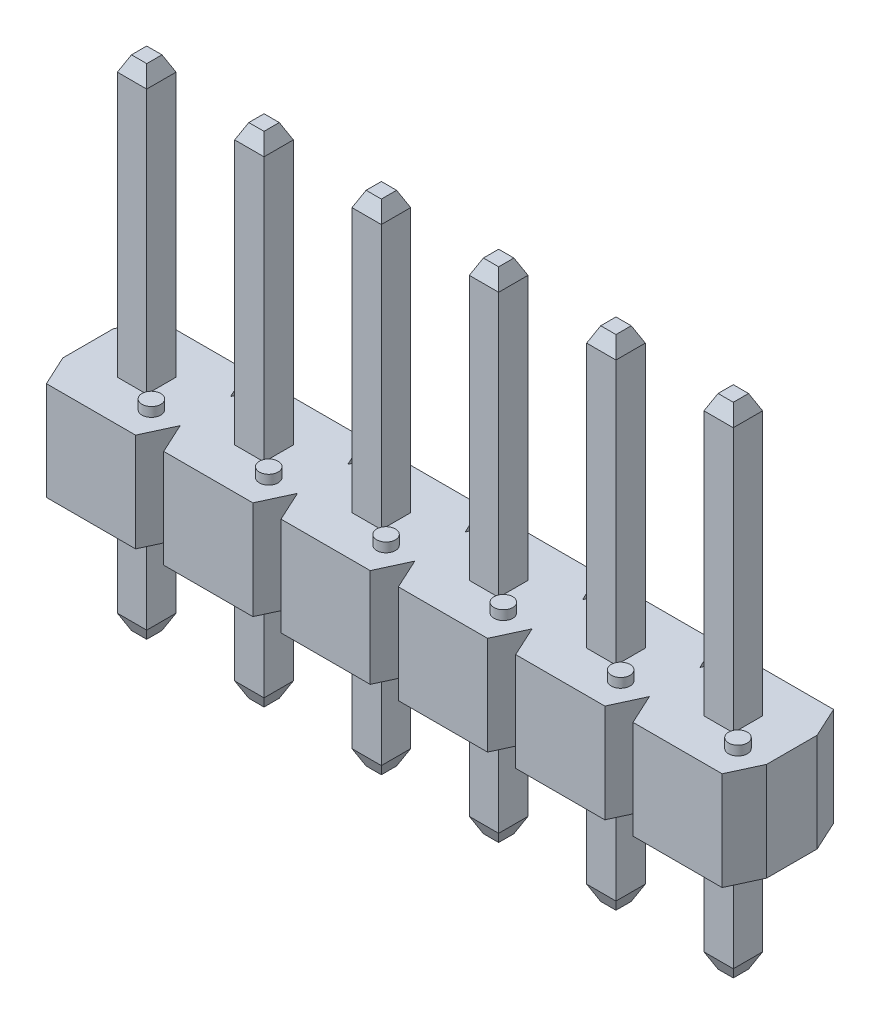
from build123d import *

# Parameters (mm, degrees)
SKETCH1_W              = 15.24
SKETCH1_H              = 2.413
BOSS_EXTRUDE1_DEPTH    = 2.1336
CUT_EXTRUDE1_DEPTH     = 3.1336
CUT_EXTRUDE2_DEPTH     = 3.1336
CUT_EXTRUDE3_DEPTH     = 3.1336
CUT_EXTRUDE4_DEPTH     = 3.1336
CUT_EXTRUDE5_DEPTH     = 3.1336
CUT_EXTRUDE6_DEPTH     = 3.1336
CUT_EXTRUDE7_DEPTH     = 3.1336
CUT_EXTRUDE8_DEPTH     = 3.1336
CUT_EXTRUDE9_DEPTH     = 3.1336
CUT_EXTRUDE10_DEPTH    = 3.1336
SKETCH12_W             = 0.635
SKETCH12_H             = 0.635
BOSS_EXTRUDE2_DEPTH    = 6.0452
SKETCH13_W             = 0.635
SKETCH13_H             = 0.635
BOSS_EXTRUDE3_DEPTH    = 6.0452
SKETCH14_W             = 0.635
SKETCH14_H             = 0.635
BOSS_EXTRUDE4_DEPTH    = 6.0452
SKETCH15_W             = 0.635
SKETCH15_H             = 0.635
BOSS_EXTRUDE5_DEPTH    = 6.0452
SKETCH16_W             = 0.635
SKETCH16_H             = 0.635
BOSS_EXTRUDE6_DEPTH    = 6.0452
SKETCH17_W             = 0.635
SKETCH17_H             = 0.635
BOSS_EXTRUDE7_DEPTH    = 6.0452
SKETCH18_W             = 0.635
SKETCH18_H             = 0.635
BOSS_EXTRUDE8_DEPTH    = 2.6162
SKETCH19_W             = 0.635
SKETCH19_H             = 0.635
BOSS_EXTRUDE9_DEPTH    = 2.6162
SKETCH20_W             = 0.635
SKETCH20_H             = 0.635
BOSS_EXTRUDE10_DEPTH   = 2.6162
SKETCH21_W             = 0.635
SKETCH21_H             = 0.635
BOSS_EXTRUDE11_DEPTH   = 2.6162
SKETCH22_W             = 0.635
SKETCH22_H             = 0.635
BOSS_EXTRUDE12_DEPTH   = 2.6162
SKETCH23_W             = 0.635
SKETCH23_H             = 0.635
BOSS_EXTRUDE13_DEPTH   = 2.6162
DRAFT1_ANGLE           = 24.775140569
DRAFT2_ANGLE           = 24.775140569
DRAFT3_ANGLE           = 24.775140569
DRAFT4_ANGLE           = 24.775140569
DRAFT5_ANGLE           = 24.775140569
DRAFT6_ANGLE           = 24.775140569
SKETCH24_W             = 0.2032
SKETCH24_H             = 0.2032
SKETCH25_W             = 0.2032
SKETCH25_H             = 0.2032
SKETCH26_W             = 0.2032
SKETCH26_H             = 0.2032
SKETCH27_W             = 0.2032
SKETCH27_H             = 0.2032
SKETCH28_W             = 0.2032
SKETCH28_H             = 0.2032
SKETCH29_W             = 0.2032
SKETCH29_H             = 0.2032
SKETCH30_W             = 0.2032
SKETCH30_H             = 0.2032
SKETCH31_W             = 0.2032
SKETCH31_H             = 0.2032
SKETCH32_W             = 0.2032
SKETCH32_H             = 0.2032
SKETCH33_W             = 0.2032
SKETCH33_H             = 0.2032
SKETCH34_W             = 0.2032
SKETCH34_H             = 0.2032
SKETCH35_W             = 0.2032
SKETCH35_H             = 0.2032
SKETCH36_W             = 0.2032
SKETCH36_H             = 0.2032
SKETCH37_W             = 0.2032
SKETCH37_H             = 0.2032
SKETCH38_W             = 0.2032
SKETCH38_H             = 0.2032
SKETCH39_W             = 0.2032
SKETCH39_H             = 0.2032
SKETCH40_W             = 0.2032
SKETCH40_H             = 0.2032
SKETCH41_W             = 0.2032
SKETCH41_H             = 0.2032
SKETCH42_W             = 0.2032
SKETCH42_H             = 0.2032
SKETCH43_W             = 0.2032
SKETCH43_H             = 0.2032
SKETCH44_W             = 0.2032
SKETCH44_H             = 0.2032
SKETCH45_W             = 0.2032
SKETCH45_H             = 0.2032
SKETCH46_W             = 0.2032
SKETCH46_H             = 0.2032
SKETCH47_W             = 0.2032
SKETCH47_H             = 0.2032
CHAMFER1_SIZE          = 0.3048
CHAMFER1_SIZE2         = 0.6604
CHAMFER1_PART_2_SIZE   = 0.3048
CHAMFER1_PART_2_SIZE2  = 0.6604
CHAMFER2_SIZE          = 0.6604
CHAMFER2_SIZE2         = 0.3048
CHAMFER2_PART_2_SIZE   = 0.6604
CHAMFER2_PART_2_SIZE2  = 0.3048
CHAMFER3_SIZE          = 0.1524
CHAMFER3_SIZE2         = 0.32512
CHAMFER3_PART_2_SIZE   = 0.1524
CHAMFER3_PART_2_SIZE2  = 0.32512
CHAMFER3_PART_3_SIZE   = 0.1524
CHAMFER3_PART_3_SIZE2  = 0.32512
CHAMFER3_PART_4_SIZE   = 0.1524
CHAMFER3_PART_4_SIZE2  = 0.32512
CHAMFER3_PART_5_SIZE   = 0.1524
CHAMFER3_PART_5_SIZE2  = 0.32512
CHAMFER3_PART_6_SIZE   = 0.1524
CHAMFER3_PART_6_SIZE2  = 0.32512
CHAMFER3_PART_7_SIZE   = 0.1524
CHAMFER3_PART_7_SIZE2  = 0.32512
CHAMFER3_PART_8_SIZE   = 0.1524
CHAMFER3_PART_8_SIZE2  = 0.32512
CHAMFER3_PART_9_SIZE   = 0.1524
CHAMFER3_PART_9_SIZE2  = 0.32512
CHAMFER3_PART_10_SIZE  = 0.1524
CHAMFER3_PART_10_SIZE2 = 0.32512
CHAMFER3_PART_11_SIZE  = 0.1524
CHAMFER3_PART_11_SIZE2 = 0.32512
CHAMFER3_PART_12_SIZE  = 0.1524
CHAMFER3_PART_12_SIZE2 = 0.32512


with BuildPart() as part:
    # Sketch1 → Boss-Extrude1 (new body)
    with BuildSketch(Plane(origin=(0, 2.1336, 0), x_dir=(1, 0, 0), z_dir=(0, 1, 0))):
        with Locations((6.35, 0)):
            Rectangle(SKETCH1_W, SKETCH1_H)
    extrude(amount=-BOSS_EXTRUDE1_DEPTH)

    # Sketch2 → Cut-Extrude1 (cut, through all)
    with BuildSketch(Plane.XZ):
        Polygon((11.7348, 1.2065), (11.1252, 1.2065), (11.7348, -0.1143), align=None)
    extrude(amount=-CUT_EXTRUDE1_DEPTH, mode=Mode.SUBTRACT)

    # Sketch3 → Cut-Extrude2 (cut, through all)
    with BuildSketch(Plane.XZ):
        Polygon((11.1252, -1.2065), (11.7348, -1.2065), (11.1252, 0.1143), align=None)
    extrude(amount=-CUT_EXTRUDE2_DEPTH, mode=Mode.SUBTRACT)

    # Sketch4 → Cut-Extrude3 (cut, through all)
    with BuildSketch(Plane.XZ):
        Polygon((8.5852, -1.2065), (9.1948, -1.2065), (9.1948, 0.1143), align=None)
    extrude(amount=-CUT_EXTRUDE3_DEPTH, mode=Mode.SUBTRACT)

    # Sketch5 → Cut-Extrude4 (cut, through all)
    with BuildSketch(Plane.XZ):
        Polygon((6.0452, -1.2065), (6.6548, -1.2065), (6.0452, 0.1143), align=None)
    extrude(amount=-CUT_EXTRUDE4_DEPTH, mode=Mode.SUBTRACT)

    # Sketch6 → Cut-Extrude5 (cut, through all)
    with BuildSketch(Plane.XZ):
        Polygon((3.5052, -1.2065), (4.1148, -1.2065), (4.1148, 0.1143), align=None)
    extrude(amount=-CUT_EXTRUDE5_DEPTH, mode=Mode.SUBTRACT)

    # Sketch7 → Cut-Extrude6 (cut, through all)
    with BuildSketch(Plane.XZ):
        Polygon((0.9652, -1.2065), (1.5748, -1.2065), (0.9652, 0.1143), align=None)
    extrude(amount=-CUT_EXTRUDE6_DEPTH, mode=Mode.SUBTRACT)

    # Sketch8 → Cut-Extrude7 (cut, through all)
    with BuildSketch(Plane.XZ):
        Polygon((1.5748, 1.2065), (0.9652, 1.2065), (1.5748, -0.1143), align=None)
    extrude(amount=-CUT_EXTRUDE7_DEPTH, mode=Mode.SUBTRACT)

    # Sketch9 → Cut-Extrude8 (cut, through all)
    with BuildSketch(Plane.XZ):
        Polygon((4.1148, 1.2065), (3.5052, 1.2065), (3.5052, -0.1143), align=None)
    extrude(amount=-CUT_EXTRUDE8_DEPTH, mode=Mode.SUBTRACT)

    # Sketch10 → Cut-Extrude9 (cut, through all)
    with BuildSketch(Plane.XZ):
        Polygon((6.6548, 1.2065), (6.0452, 1.2065), (6.6548, -0.1143), align=None)
    extrude(amount=-CUT_EXTRUDE9_DEPTH, mode=Mode.SUBTRACT)

    # Sketch11 → Cut-Extrude10 (cut, through all)
    with BuildSketch(Plane.XZ):
        Polygon((9.1948, 1.2065), (8.5852, 1.2065), (8.5852, -0.1143), align=None)
    extrude(amount=-CUT_EXTRUDE10_DEPTH, mode=Mode.SUBTRACT)

    # Sketch12 → Boss-Extrude2 (add)
    with BuildSketch(Plane(origin=(0, 2.1336, 0), x_dir=(-1, 0, 0), z_dir=(0, 1, 0))):
        Rectangle(SKETCH12_W, SKETCH12_H)
    extrude(amount=BOSS_EXTRUDE2_DEPTH)

    # Sketch13 → Boss-Extrude3 (add)
    with BuildSketch(Plane(origin=(0, 2.1336, 0), x_dir=(-1, 0, 0), z_dir=(0, 1, 0))):
        with Locations((-2.54, 0)):
            Rectangle(SKETCH13_W, SKETCH13_H)
    extrude(amount=BOSS_EXTRUDE3_DEPTH)

    # Sketch14 → Boss-Extrude4 (add)
    with BuildSketch(Plane(origin=(0, 2.1336, 0), x_dir=(-1, 0, 0), z_dir=(0, 1, 0))):
        with Locations((-5.08, 0)):
            Rectangle(SKETCH14_W, SKETCH14_H)
    extrude(amount=BOSS_EXTRUDE4_DEPTH)

    # Sketch15 → Boss-Extrude5 (add)
    with BuildSketch(Plane(origin=(0, 2.1336, 0), x_dir=(-1, 0, 0), z_dir=(0, 1, 0))):
        with Locations((-7.62, 0)):
            Rectangle(SKETCH15_W, SKETCH15_H)
    extrude(amount=BOSS_EXTRUDE5_DEPTH)

    # Sketch16 → Boss-Extrude6 (add)
    with BuildSketch(Plane(origin=(0, 2.1336, 0), x_dir=(-1, 0, 0), z_dir=(0, 1, 0))):
        with Locations((-10.16, 0)):
            Rectangle(SKETCH16_W, SKETCH16_H)
    extrude(amount=BOSS_EXTRUDE6_DEPTH)

    # Sketch17 → Boss-Extrude7 (add)
    with BuildSketch(Plane(origin=(0, 2.1336, 0), x_dir=(-1, 0, 0), z_dir=(0, 1, 0))):
        with Locations((-12.7, 0)):
            Rectangle(SKETCH17_W, SKETCH17_H)
    extrude(amount=BOSS_EXTRUDE7_DEPTH)

    # Sketch18 → Boss-Extrude8 (add)
    with BuildSketch(Plane.XZ):
        Rectangle(SKETCH18_W, SKETCH18_H)
    extrude(amount=BOSS_EXTRUDE8_DEPTH)

    # Sketch19 → Boss-Extrude9 (add)
    with BuildSketch(Plane.XZ):
        with Locations((2.54, 0)):
            Rectangle(SKETCH19_W, SKETCH19_H)
    extrude(amount=BOSS_EXTRUDE9_DEPTH)

    # Sketch20 → Boss-Extrude10 (add)
    with BuildSketch(Plane.XZ):
        with Locations((5.08, 0)):
            Rectangle(SKETCH20_W, SKETCH20_H)
    extrude(amount=BOSS_EXTRUDE10_DEPTH)

    # Sketch21 → Boss-Extrude11 (add)
    with BuildSketch(Plane.XZ):
        with Locations((7.62, 0)):
            Rectangle(SKETCH21_W, SKETCH21_H)
    extrude(amount=BOSS_EXTRUDE11_DEPTH)

    # Sketch22 → Boss-Extrude12 (add)
    with BuildSketch(Plane.XZ):
        with Locations((10.16, 0)):
            Rectangle(SKETCH22_W, SKETCH22_H)
    extrude(amount=BOSS_EXTRUDE12_DEPTH)

    # Sketch23 → Boss-Extrude13 (add)
    with BuildSketch(Plane.XZ):
        with Locations((12.7, 0)):
            Rectangle(SKETCH23_W, SKETCH23_H)
    extrude(amount=BOSS_EXTRUDE13_DEPTH)

    # Draft1
    draft1_faces = [part.faces().sort_by_distance(p)[0] for p in [
        (0.9652, 1.0668, -0.5461),
    ]]
    draft(draft1_faces, Plane(origin=(13.97, 0, -1.2065), x_dir=(-1, 0, 0), z_dir=(0, 0, -1)), DRAFT1_ANGLE)

    # Draft2
    draft2_faces = [part.faces().sort_by_distance(p)[0] for p in [
        (11.7348, 1.0668, 0.5461),
    ]]
    draft(draft2_faces, Plane(origin=(-1.27, 0, 1.2065), x_dir=(1, 0, 0), z_dir=(0, 0, 1)), DRAFT2_ANGLE)

    # Draft3
    draft3_faces = [part.faces().sort_by_distance(p)[0] for p in [
        (8.5852, 1.0668, 0.5461),
        (6.6548, 1.0668, 0.5461),
    ]]
    draft(draft3_faces, Plane(origin=(-1.27, 0, 1.2065), x_dir=(1, 0, 0), z_dir=(0, 0, 1)), DRAFT3_ANGLE)

    # Draft4
    draft4_faces = [part.faces().sort_by_distance(p)[0] for p in [
        (3.5052, 1.0668, 0.5461),
        (1.5748, 1.0668, 0.5461),
    ]]
    draft(draft4_faces, Plane(origin=(-1.27, 0, 1.2065), x_dir=(1, 0, 0), z_dir=(0, 0, 1)), DRAFT4_ANGLE)

    # Draft5
    draft5_faces = [part.faces().sort_by_distance(p)[0] for p in [
        (6.0452, 1.0668, -0.5461),
        (4.1148, 1.0668, -0.5461),
    ]]
    draft(draft5_faces, Plane(origin=(13.97, 0, -1.2065), x_dir=(-1, 0, 0), z_dir=(0, 0, -1)), DRAFT5_ANGLE)

    # Draft6
    draft6_faces = [part.faces().sort_by_distance(p)[0] for p in [
        (11.1252, 1.0668, -0.5461),
        (9.1948, 1.0668, -0.5461),
    ]]
    draft(draft6_faces, Plane(origin=(13.97, 0, -1.2065), x_dir=(-1, 0, 0), z_dir=(0, 0, -1)), DRAFT6_ANGLE)

    # Sketch24 → Revolve1 (revolve)
    with BuildSketch(Plane.XY.offset(-0.5588)):
        with Locations((-0.5588, -0.1016)):
            Rectangle(SKETCH24_W, SKETCH24_H)
    revolve(axis=Axis((-0.6604, 0, -0.5588), (0, -1, 0)))

    # Sketch25 → Revolve2 (revolve)
    with BuildSketch(Plane.XY.offset(0.5588)):
        with Locations((0.762, -0.1016)):
            Rectangle(SKETCH25_W, SKETCH25_H)
    revolve(axis=Axis((0.6604, 0, 0.5588), (0, -1, 0)))

    # Sketch26 → Revolve3 (revolve)
    with BuildSketch(Plane.XY.offset(0.5588)):
        with Locations((3.302, -0.1016)):
            Rectangle(SKETCH26_W, SKETCH26_H)
    revolve(axis=Axis((3.2004, 0, 0.5588), (0, -1, 0)))

    # Sketch27 → Revolve4 (revolve)
    with BuildSketch(Plane.XY.offset(-0.5588)):
        with Locations((1.9812, -0.1016)):
            Rectangle(SKETCH27_W, SKETCH27_H)
    revolve(axis=Axis((1.8796, 0, -0.5588), (0, -1, 0)))

    # Sketch28 → Revolve5 (revolve)
    with BuildSketch(Plane.XY.offset(0.5588)):
        with Locations((5.842, -0.1016)):
            Rectangle(SKETCH28_W, SKETCH28_H)
    revolve(axis=Axis((5.7404, 0, 0.5588), (0, -1, 0)))

    # Sketch29 → Revolve6 (revolve)
    with BuildSketch(Plane.XY.offset(-0.5588)):
        with Locations((4.5212, -0.1016)):
            Rectangle(SKETCH29_W, SKETCH29_H)
    revolve(axis=Axis((4.4196, 0, -0.5588), (0, -1, 0)))

    # Sketch30 → Revolve7 (revolve)
    with BuildSketch(Plane.XY.offset(0.5588)):
        with Locations((8.382, -0.1016)):
            Rectangle(SKETCH30_W, SKETCH30_H)
    revolve(axis=Axis((8.2804, 0, 0.5588), (0, -1, 0)))

    # Sketch31 → Revolve8 (revolve)
    with BuildSketch(Plane.XY.offset(-0.5588)):
        with Locations((7.0612, -0.1016)):
            Rectangle(SKETCH31_W, SKETCH31_H)
    revolve(axis=Axis((6.9596, 0, -0.5588), (0, -1, 0)))

    # Sketch32 → Revolve9 (revolve)
    with BuildSketch(Plane.XY.offset(0.5588)):
        with Locations((10.922, -0.1016)):
            Rectangle(SKETCH32_W, SKETCH32_H)
    revolve(axis=Axis((10.8204, 0, 0.5588), (0, -1, 0)))

    # Sketch33 → Revolve10 (revolve)
    with BuildSketch(Plane.XY.offset(-0.5588)):
        with Locations((9.6012, -0.1016)):
            Rectangle(SKETCH33_W, SKETCH33_H)
    revolve(axis=Axis((9.4996, 0, -0.5588), (0, -1, 0)))

    # Sketch34 → Revolve11 (revolve)
    with BuildSketch(Plane.XY.offset(0.5588)):
        with Locations((13.462, -0.1016)):
            Rectangle(SKETCH34_W, SKETCH34_H)
    revolve(axis=Axis((13.3604, 0, 0.5588), (0, -1, 0)))

    # Sketch35 → Revolve12 (revolve)
    with BuildSketch(Plane.XY.offset(-0.5588)):
        with Locations((12.1412, -0.1016)):
            Rectangle(SKETCH35_W, SKETCH35_H)
    revolve(axis=Axis((12.0396, 0, -0.5588), (0, -1, 0)))

    # Sketch36 → Revolve13 (revolve)
    with BuildSketch(Plane(origin=(0, 0, 0.5588), x_dir=(-1, 0, 0), z_dir=(0, 0, -1))):
        with Locations((-0.762, 2.2352)):
            Rectangle(SKETCH36_W, SKETCH36_H)
    revolve(axis=Axis((0.6604, 2.1336, 0.5588), (0, 1, 0)))

    # Sketch37 → Revolve14 (revolve)
    with BuildSketch(Plane(origin=(0, 0, -0.5588), x_dir=(-1, 0, 0), z_dir=(0, 0, -1))):
        with Locations((0.5588, 2.2352)):
            Rectangle(SKETCH37_W, SKETCH37_H)
    revolve(axis=Axis((-0.6604, 2.1336, -0.5588), (0, 1, 0)))

    # Sketch38 → Revolve15 (revolve)
    with BuildSketch(Plane(origin=(0, 0, -0.5588), x_dir=(-1, 0, 0), z_dir=(0, 0, -1))):
        with Locations((-1.9812, 2.2352)):
            Rectangle(SKETCH38_W, SKETCH38_H)
    revolve(axis=Axis((1.8796, 2.1336, -0.5588), (0, 1, 0)))

    # Sketch39 → Revolve16 (revolve)
    with BuildSketch(Plane(origin=(0, 0, 0.5588), x_dir=(-1, 0, 0), z_dir=(0, 0, -1))):
        with Locations((-3.302, 2.2352)):
            Rectangle(SKETCH39_W, SKETCH39_H)
    revolve(axis=Axis((3.2004, 2.1336, 0.5588), (0, 1, 0)))

    # Sketch40 → Revolve17 (revolve)
    with BuildSketch(Plane(origin=(0, 0, -0.5588), x_dir=(-1, 0, 0), z_dir=(0, 0, -1))):
        with Locations((-4.5212, 2.2352)):
            Rectangle(SKETCH40_W, SKETCH40_H)
    revolve(axis=Axis((4.4196, 2.1336, -0.5588), (0, 1, 0)))

    # Sketch41 → Revolve18 (revolve)
    with BuildSketch(Plane(origin=(0, 0, 0.5588), x_dir=(-1, 0, 0), z_dir=(0, 0, -1))):
        with Locations((-5.842, 2.2352)):
            Rectangle(SKETCH41_W, SKETCH41_H)
    revolve(axis=Axis((5.7404, 2.1336, 0.5588), (0, 1, 0)))

    # Sketch42 → Revolve19 (revolve)
    with BuildSketch(Plane(origin=(0, 0, -0.5588), x_dir=(-1, 0, 0), z_dir=(0, 0, -1))):
        with Locations((-7.0612, 2.2352)):
            Rectangle(SKETCH42_W, SKETCH42_H)
    revolve(axis=Axis((6.9596, 2.1336, -0.5588), (0, 1, 0)))

    # Sketch43 → Revolve20 (revolve)
    with BuildSketch(Plane(origin=(0, 0, 0.5588), x_dir=(-1, 0, 0), z_dir=(0, 0, -1))):
        with Locations((-8.382, 2.2352)):
            Rectangle(SKETCH43_W, SKETCH43_H)
    revolve(axis=Axis((8.2804, 2.1336, 0.5588), (0, 1, 0)))

    # Sketch44 → Revolve21 (revolve)
    with BuildSketch(Plane(origin=(0, 0, -0.5588), x_dir=(-1, 0, 0), z_dir=(0, 0, -1))):
        with Locations((-9.6012, 2.2352)):
            Rectangle(SKETCH44_W, SKETCH44_H)
    revolve(axis=Axis((9.4996, 2.1336, -0.5588), (0, 1, 0)))

    # Sketch45 → Revolve22 (revolve)
    with BuildSketch(Plane(origin=(0, 0, 0.5588), x_dir=(-1, 0, 0), z_dir=(0, 0, -1))):
        with Locations((-10.922, 2.2352)):
            Rectangle(SKETCH45_W, SKETCH45_H)
    revolve(axis=Axis((10.8204, 2.1336, 0.5588), (0, 1, 0)))

    # Sketch46 → Revolve23 (revolve)
    with BuildSketch(Plane(origin=(0, 0, -0.5588), x_dir=(-1, 0, 0), z_dir=(0, 0, -1))):
        with Locations((-12.1412, 2.2352)):
            Rectangle(SKETCH46_W, SKETCH46_H)
    revolve(axis=Axis((12.0396, 2.1336, -0.5588), (0, 1, 0)))

    # Sketch47 → Revolve24 (revolve)
    with BuildSketch(Plane(origin=(0, 0, 0.5588), x_dir=(-1, 0, 0), z_dir=(0, 0, -1))):
        with Locations((-13.462, 2.2352)):
            Rectangle(SKETCH47_W, SKETCH47_H)
    revolve(axis=Axis((13.3604, 2.1336, 0.5588), (0, 1, 0)))

    # Chamfer1
    chamfer1_edges = [part.edges().sort_by_distance(p)[0] for p in [
        (-1.27, 1.0668, -1.2065),
    ]]
    chamfer1_side = [part.faces().sort_by_distance(p)[0] for p in [
        (-0.1524, 1.0668, -1.2065),
    ]]
    chamfer(chamfer1_edges, length=CHAMFER1_SIZE, length2=CHAMFER1_SIZE2, reference=chamfer1_side[0])

    # Chamfer1 part 2
    chamfer1_part_2_edges = [part.edges().sort_by_distance(p)[0] for p in [
        (13.97, 1.0668, 1.2065),
    ]]
    chamfer1_part_2_side = [part.faces().sort_by_distance(p)[0] for p in [
        (12.8524, 1.0668, 1.2065),
    ]]
    chamfer(chamfer1_part_2_edges, length=CHAMFER1_PART_2_SIZE, length2=CHAMFER1_PART_2_SIZE2, reference=chamfer1_part_2_side[0])

    # Chamfer2
    chamfer2_edges = [part.edges().sort_by_distance(p)[0] for p in [
        (-1.27, 1.0668, 1.2065),
    ]]
    chamfer2_side = [part.faces().sort_by_distance(p)[0] for p in [
        (-1.27, 1.0668, 0.3302),
    ]]
    chamfer(chamfer2_edges, length=CHAMFER2_SIZE, length2=CHAMFER2_SIZE2, reference=chamfer2_side[0])

    # Chamfer2 part 2
    chamfer2_part_2_edges = [part.edges().sort_by_distance(p)[0] for p in [
        (13.97, 1.0668, -1.2065),
    ]]
    chamfer2_part_2_side = [part.faces().sort_by_distance(p)[0] for p in [
        (13.97, 1.0668, -0.3302),
    ]]
    chamfer(chamfer2_part_2_edges, length=CHAMFER2_PART_2_SIZE, length2=CHAMFER2_PART_2_SIZE2, reference=chamfer2_part_2_side[0])

    # Chamfer3
    chamfer3_edges = [part.edges().sort_by_distance(p)[0] for p in [
        (0.3175, 8.1788, 0),
        (0, 8.1788, -0.3175),
        (-0.3175, 8.1788, 0),
        (0, 8.1788, 0.3175),
    ]]
    chamfer3_side = [part.faces().sort_by_distance(p)[0] for p in [
        (0, 8.1788, 0),
    ]]
    chamfer(chamfer3_edges, length=CHAMFER3_SIZE, length2=CHAMFER3_SIZE2, reference=chamfer3_side[0])

    # Chamfer3 part 2
    chamfer3_part_2_edges = [part.edges().sort_by_distance(p)[0] for p in [
        (2.54, 8.1788, -0.3175),
        (2.2225, 8.1788, 0),
        (2.54, 8.1788, 0.3175),
        (2.8575, 8.1788, 0),
    ]]
    chamfer3_part_2_side = [part.faces().sort_by_distance(p)[0] for p in [
        (2.54, 8.1788, 0),
    ]]
    chamfer(chamfer3_part_2_edges, length=CHAMFER3_PART_2_SIZE, length2=CHAMFER3_PART_2_SIZE2, reference=chamfer3_part_2_side[0])

    # Chamfer3 part 3
    chamfer3_part_3_edges = [part.edges().sort_by_distance(p)[0] for p in [
        (5.08, 8.1788, -0.3175),
        (4.7625, 8.1788, 0),
        (5.08, 8.1788, 0.3175),
        (5.3975, 8.1788, 0),
    ]]
    chamfer3_part_3_side = [part.faces().sort_by_distance(p)[0] for p in [
        (5.08, 8.1788, 0),
    ]]
    chamfer(chamfer3_part_3_edges, length=CHAMFER3_PART_3_SIZE, length2=CHAMFER3_PART_3_SIZE2, reference=chamfer3_part_3_side[0])

    # Chamfer3 part 4
    chamfer3_part_4_edges = [part.edges().sort_by_distance(p)[0] for p in [
        (7.62, 8.1788, -0.3175),
        (7.3025, 8.1788, 0),
        (7.62, 8.1788, 0.3175),
        (7.9375, 8.1788, 0),
    ]]
    chamfer3_part_4_side = [part.faces().sort_by_distance(p)[0] for p in [
        (7.62, 8.1788, 0),
    ]]
    chamfer(chamfer3_part_4_edges, length=CHAMFER3_PART_4_SIZE, length2=CHAMFER3_PART_4_SIZE2, reference=chamfer3_part_4_side[0])

    # Chamfer3 part 5
    chamfer3_part_5_edges = [part.edges().sort_by_distance(p)[0] for p in [
        (10.16, 8.1788, -0.3175),
        (9.8425, 8.1788, 0),
        (10.16, 8.1788, 0.3175),
        (10.4775, 8.1788, 0),
    ]]
    chamfer3_part_5_side = [part.faces().sort_by_distance(p)[0] for p in [
        (10.16, 8.1788, 0),
    ]]
    chamfer(chamfer3_part_5_edges, length=CHAMFER3_PART_5_SIZE, length2=CHAMFER3_PART_5_SIZE2, reference=chamfer3_part_5_side[0])

    # Chamfer3 part 6
    chamfer3_part_6_edges = [part.edges().sort_by_distance(p)[0] for p in [
        (12.7, 8.1788, -0.3175),
        (12.3825, 8.1788, 0),
        (12.7, 8.1788, 0.3175),
        (13.0175, 8.1788, 0),
    ]]
    chamfer3_part_6_side = [part.faces().sort_by_distance(p)[0] for p in [
        (12.7, 8.1788, 0),
    ]]
    chamfer(chamfer3_part_6_edges, length=CHAMFER3_PART_6_SIZE, length2=CHAMFER3_PART_6_SIZE2, reference=chamfer3_part_6_side[0])

    # Chamfer3 part 7
    chamfer3_part_7_edges = [part.edges().sort_by_distance(p)[0] for p in [
        (0.3175, -2.6162, 0),
        (0, -2.6162, 0.3175),
        (-0.3175, -2.6162, 0),
        (0, -2.6162, -0.3175),
    ]]
    chamfer3_part_7_side = [part.faces().sort_by_distance(p)[0] for p in [
        (0, -2.6162, 0),
    ]]
    chamfer(chamfer3_part_7_edges, length=CHAMFER3_PART_7_SIZE, length2=CHAMFER3_PART_7_SIZE2, reference=chamfer3_part_7_side[0])

    # Chamfer3 part 8
    chamfer3_part_8_edges = [part.edges().sort_by_distance(p)[0] for p in [
        (2.54, -2.6162, 0.3175),
        (2.2225, -2.6162, 0),
        (2.54, -2.6162, -0.3175),
        (2.8575, -2.6162, 0),
    ]]
    chamfer3_part_8_side = [part.faces().sort_by_distance(p)[0] for p in [
        (2.54, -2.6162, 0),
    ]]
    chamfer(chamfer3_part_8_edges, length=CHAMFER3_PART_8_SIZE, length2=CHAMFER3_PART_8_SIZE2, reference=chamfer3_part_8_side[0])

    # Chamfer3 part 9
    chamfer3_part_9_edges = [part.edges().sort_by_distance(p)[0] for p in [
        (5.3975, -2.6162, 0),
        (5.08, -2.6162, 0.3175),
        (4.7625, -2.6162, 0),
        (5.08, -2.6162, -0.3175),
    ]]
    chamfer3_part_9_side = [part.faces().sort_by_distance(p)[0] for p in [
        (5.08, -2.6162, 0),
    ]]
    chamfer(chamfer3_part_9_edges, length=CHAMFER3_PART_9_SIZE, length2=CHAMFER3_PART_9_SIZE2, reference=chamfer3_part_9_side[0])

    # Chamfer3 part 10
    chamfer3_part_10_edges = [part.edges().sort_by_distance(p)[0] for p in [
        (7.62, -2.6162, -0.3175),
        (7.9375, -2.6162, 0),
        (7.62, -2.6162, 0.3175),
        (7.3025, -2.6162, 0),
    ]]
    chamfer3_part_10_side = [part.faces().sort_by_distance(p)[0] for p in [
        (7.62, -2.6162, 0),
    ]]
    chamfer(chamfer3_part_10_edges, length=CHAMFER3_PART_10_SIZE, length2=CHAMFER3_PART_10_SIZE2, reference=chamfer3_part_10_side[0])

    # Chamfer3 part 11
    chamfer3_part_11_edges = [part.edges().sort_by_distance(p)[0] for p in [
        (10.4775, -2.6162, 0),
        (10.16, -2.6162, 0.3175),
        (9.8425, -2.6162, 0),
        (10.16, -2.6162, -0.3175),
    ]]
    chamfer3_part_11_side = [part.faces().sort_by_distance(p)[0] for p in [
        (10.16, -2.6162, 0),
    ]]
    chamfer(chamfer3_part_11_edges, length=CHAMFER3_PART_11_SIZE, length2=CHAMFER3_PART_11_SIZE2, reference=chamfer3_part_11_side[0])

    # Chamfer3 part 12
    chamfer3_part_12_edges = [part.edges().sort_by_distance(p)[0] for p in [
        (12.7, -2.6162, 0.3175),
        (12.3825, -2.6162, 0),
        (12.7, -2.6162, -0.3175),
        (13.0175, -2.6162, 0),
    ]]
    chamfer3_part_12_side = [part.faces().sort_by_distance(p)[0] for p in [
        (12.7, -2.6162, 0),
    ]]
    chamfer(chamfer3_part_12_edges, length=CHAMFER3_PART_12_SIZE, length2=CHAMFER3_PART_12_SIZE2, reference=chamfer3_part_12_side[0])


solid = part.part
